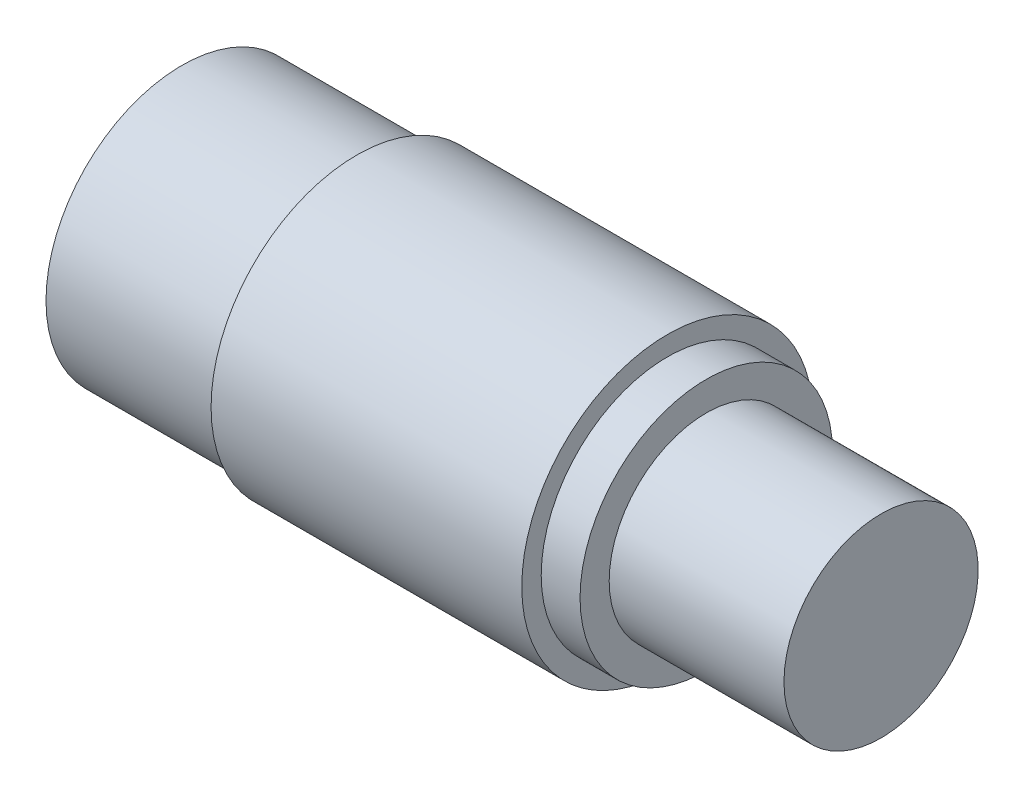
from build123d import *


with BuildPart() as part:
    # 草圖1 → 旋轉1 (revolve)
    with BuildSketch(Plane.XY):
        Polygon((-18, 0), (-18, 7), (-9, 7), (-9, 7.5), (7, 7.5), (7, 6.5), (9, 6.5), (9, 5), (18, 5), (18, 0), align=None)
    revolve(axis=Axis((-48.335020186, 0, 0), (1, 0, 0)))


solid = part.part
